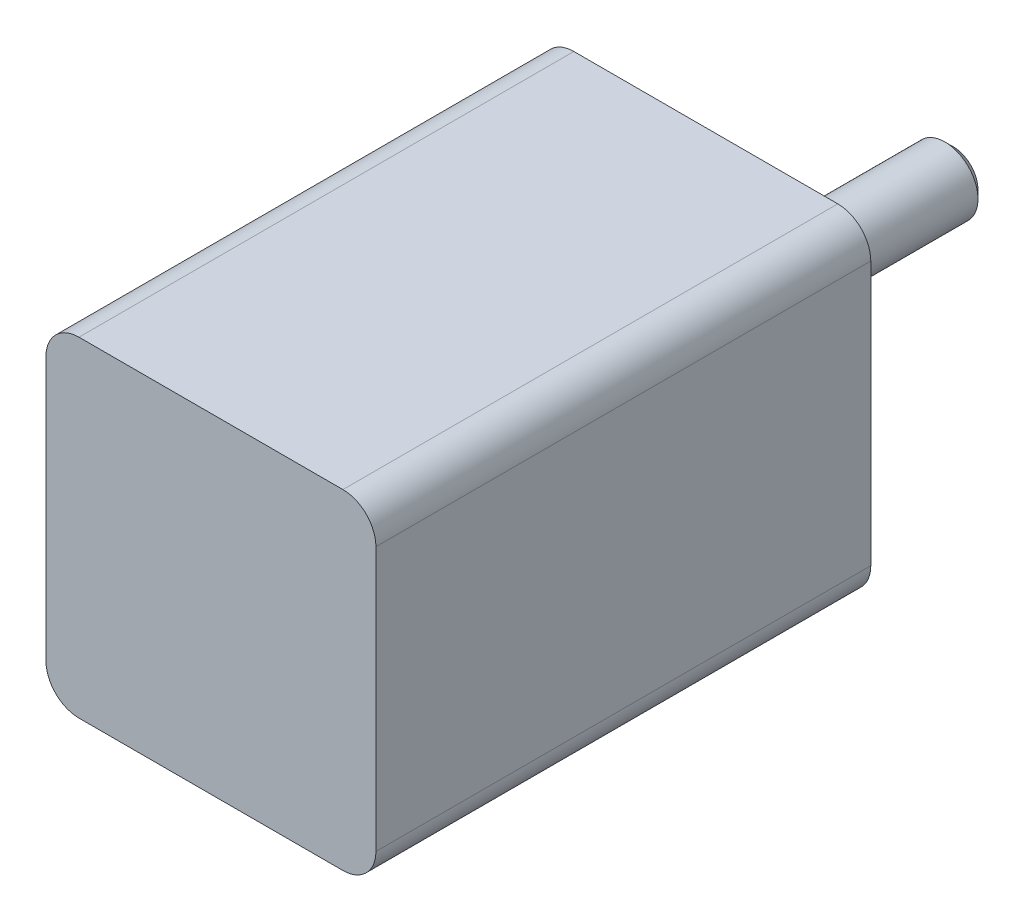
from build123d import *

# Parameters (mm, degrees)
SKETCH1_W                 = 20
SKETCH1_H                 = 20
BOSS_EXTRUDE1_DEPTH       = 30
SKETCH2_R                 = 7.5
BOSS_EXTRUDE2_DEPTH       = 1.5
SKETCH3_R                 = 2
BOSS_EXTRUDE3_DEPTH       = 13.5
M2X0_4_TAPPED_HOLE1_D     = 1.6
M2X0_4_TAPPED_HOLE1_DEPTH = 3.5
M2X0_4_TAPPED_HOLE1_TIP   = 0.480688495
FILLET1_R                 = 2
CHAMFER1_SIZE             = 0.5


with BuildPart() as part:
    # Sketch1 → Boss-Extrude1 (new body)
    with BuildSketch(Plane.XY):
        Rectangle(SKETCH1_W, SKETCH1_H)
    extrude(amount=BOSS_EXTRUDE1_DEPTH)

    # Sketch2 → Boss-Extrude2 (add)
    with BuildSketch(Plane(origin=(0, 0, 0), x_dir=(-1, 0, 0), z_dir=(0, 0, -1))):
        Circle(SKETCH2_R)
    extrude(amount=BOSS_EXTRUDE2_DEPTH)

    # Sketch3 → Boss-Extrude3 (add)
    with BuildSketch(Plane(origin=(0, 0, -1.5), x_dir=(-1, 0, 0), z_dir=(0, 0, -1))):
        Circle(SKETCH3_R)
    extrude(amount=BOSS_EXTRUDE3_DEPTH)

    # M2x0.4 Tapped Hole1
    with Locations(Plane(origin=(0, 0, 0), x_dir=(-1, 0, 0), z_dir=(0, 0, -1))):
        with Locations((-8, 8), (8, 8), (8, -8), (-8, -8)):
            Hole(M2X0_4_TAPPED_HOLE1_D / 2, depth=M2X0_4_TAPPED_HOLE1_DEPTH)
            with Locations((0, 0, -(M2X0_4_TAPPED_HOLE1_DEPTH + M2X0_4_TAPPED_HOLE1_TIP / 2))):  # 118° drill point
                Cone(0, M2X0_4_TAPPED_HOLE1_D / 2, M2X0_4_TAPPED_HOLE1_TIP, mode=Mode.SUBTRACT)

    # Fillet1
    fillet1_edges = [part.edges().sort_by_distance(p)[0] for p in [
        (10, -10, 15),
        (-10, -10, 15),
        (-10, 10, 15),
        (10, 10, 15),
    ]]
    fillet(fillet1_edges, radius=FILLET1_R)

    # Chamfer1
    chamfer1_edges = [part.edges().sort_by_distance(p)[0] for p in [
        (2, 0, -15),
    ]]
    chamfer(chamfer1_edges, length=CHAMFER1_SIZE)


solid = part.part
